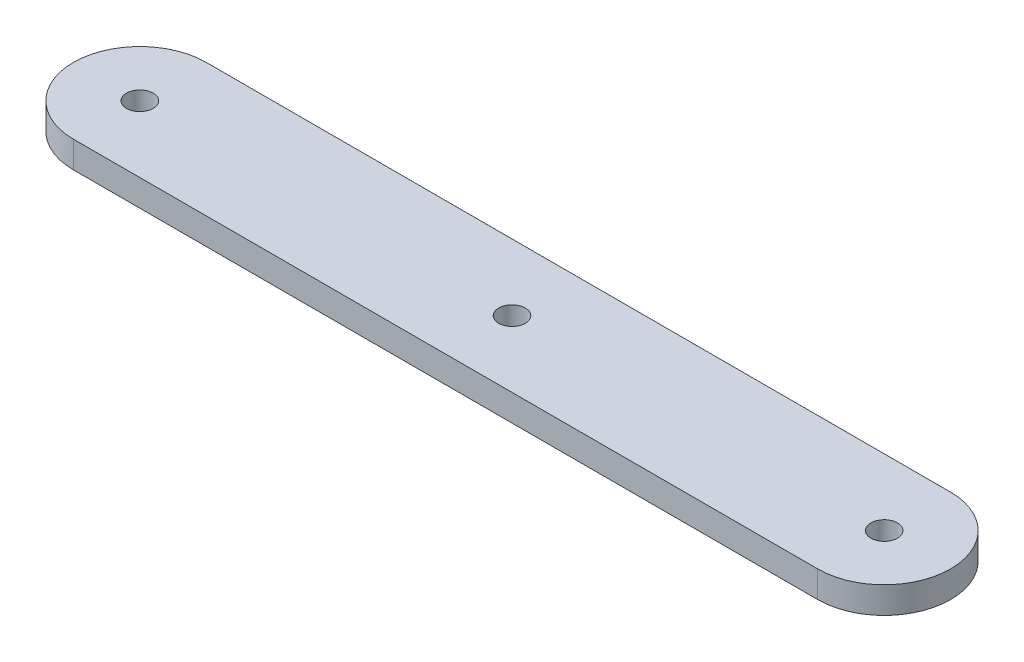
from build123d import *

# Parameters (mm, degrees)
SCHIZZO1_R                   = 0.5
ESTRUSIONE_ESTRUSIONE3_DEPTH = 0.5


with BuildPart() as part:
    # Schizzo1 → Estrusione-Estrusione3 (new body, symmetric)
    with BuildSketch(Plane(origin=(0, 0, 0), x_dir=(1, 0, 0), z_dir=(0, 1, 0))):
        with BuildLine():
            Line((-14, 2.5), (14, 2.5))
            ThreePointArc((14, 2.5), (16.5, 0), (14, -2.5))
            Line((14, -2.5), (-14, -2.5))
            ThreePointArc((-14, -2.5), (-16.5, 0), (-14, 2.5))
        make_face()
        Circle(SCHIZZO1_R, mode=Mode.SUBTRACT)
        with Locations((-14, 0)):
            Circle(SCHIZZO1_R, mode=Mode.SUBTRACT)
        with Locations((14, 0)):
            Circle(SCHIZZO1_R, mode=Mode.SUBTRACT)
    extrude(amount=ESTRUSIONE_ESTRUSIONE3_DEPTH, both=True)


solid = part.part
